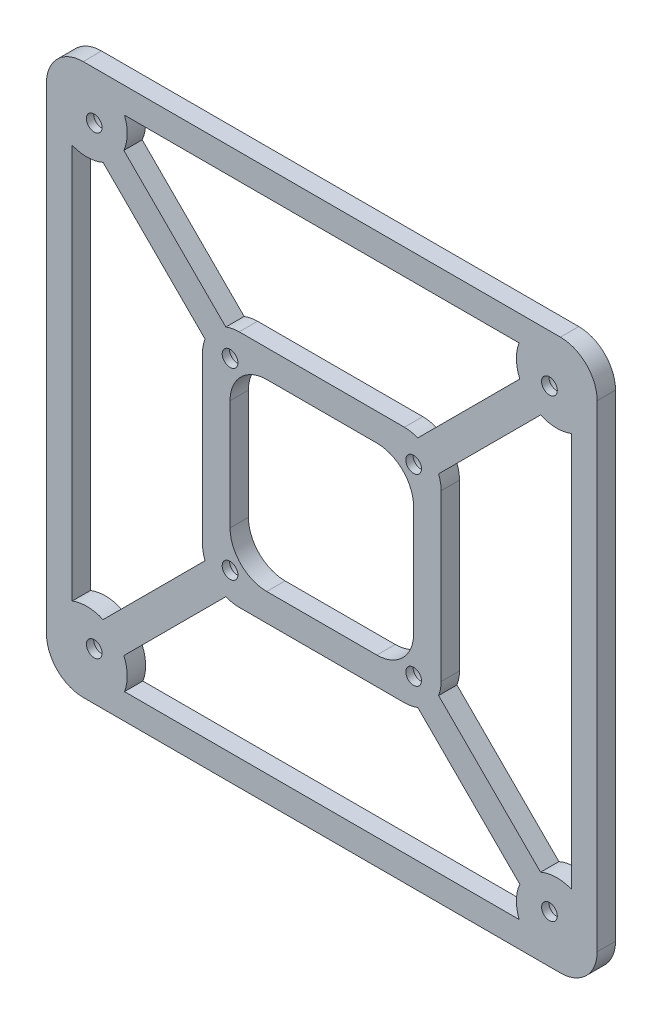
from build123d import *

# Parameters (mm, degrees)
SKETCH1_R             = 11
BOSS_EXTRUDE1_DEPTH   = 5
BOSS_EXTRUDE1_2_DEPTH = 5
BOSS_EXTRUDE1_3_DEPTH = 5
BOSS_EXTRUDE1_4_DEPTH = 5
SKETCH3_W             = 150
SKETCH3_H             = 150
SKETCH3_W_2           = 136
SKETCH3_H_2           = 136
BOSS_EXTRUDE3_DEPTH   = 5
SKETCH8_R             = 2.14
BOSS_EXTRUDE4_DEPTH   = 5
BOSS_EXTRUDE4_2_DEPTH = 5
BOSS_EXTRUDE4_3_DEPTH = 5
BOSS_EXTRUDE4_4_DEPTH = 5
FILLET1_R             = 10
SKETCH9_R             = 4
BOSS_EXTRUDE5_DEPTH   = 3
BOSS_EXTRUDE5_2_DEPTH = 3
BOSS_EXTRUDE5_3_DEPTH = 3
BOSS_EXTRUDE5_4_DEPTH = 3
SKETCH10_W            = 65
SKETCH10_H            = 65
SKETCH10_W_2          = 50
SKETCH10_H_2          = 50
BOSS_EXTRUDE6_DEPTH   = 5
FILLET2_R             = 10
SKETCH11_R            = 2.14
BOSS_EXTRUDE7_DEPTH   = 5
BOSS_EXTRUDE7_2_DEPTH = 5
BOSS_EXTRUDE7_3_DEPTH = 5
BOSS_EXTRUDE7_4_DEPTH = 5
SKETCH12_R            = 3.8
BOSS_EXTRUDE8_DEPTH   = 3
BOSS_EXTRUDE8_2_DEPTH = 3
BOSS_EXTRUDE8_3_DEPTH = 3
BOSS_EXTRUDE8_4_DEPTH = 3
BOSS_EXTRUDE9_DEPTH   = 5
BOSS_EXTRUDE9_2_DEPTH = 5
BOSS_EXTRUDE9_3_DEPTH = 5
BOSS_EXTRUDE9_4_DEPTH = 5


with BuildPart() as part:
    # Sketch1 → Boss-Extrude1 (new body)
    with BuildSketch(Plane.XY):
        with Locations((-64, -64)):
            Circle(SKETCH1_R)
    extrude(amount=BOSS_EXTRUDE1_DEPTH)


with BuildPart() as body_2:
    # Sketch1 → Boss-Extrude1 2 (new body)
    with BuildSketch(Plane.XY):
        with Locations((-64, 64)):
            Circle(SKETCH1_R)
    extrude(amount=BOSS_EXTRUDE1_2_DEPTH)



with BuildPart() as body_3:
    # Sketch1 → Boss-Extrude1 3 (new body)
    with BuildSketch(Plane.XY):
        with Locations((64, -64)):
            Circle(SKETCH1_R)
    extrude(amount=BOSS_EXTRUDE1_3_DEPTH)


with BuildPart() as body_4:
    # Sketch1 → Boss-Extrude1 4 (new body)
    with BuildSketch(Plane.XY):
        with Locations((64, 64)):
            Circle(SKETCH1_R)
    extrude(amount=BOSS_EXTRUDE1_4_DEPTH)


with BuildPart() as body_2_1:
    add(body_2.part)

    add(body_3.part)  # Boss-Extrude3 merges body 3

    add(body_4.part)  # Boss-Extrude3 merges body 4
    # Sketch3 → Boss-Extrude3 (add)
    with BuildSketch(Plane.XY):
        Rectangle(SKETCH3_W, SKETCH3_H)
        Rectangle(SKETCH3_W_2, SKETCH3_H_2, mode=Mode.SUBTRACT)
    extrude(amount=BOSS_EXTRUDE3_DEPTH)

    # Fillet1
    fillet1_edges = [body_2_1.edges().sort_by_distance(p)[0] for p in [
        (75, -75, 2.5),
        (75, 75, 2.5),
        (-75, 75, 2.5),
        (-75, -75, 2.5),
    ]]
    fillet(fillet1_edges, radius=FILLET1_R)

    # Combine1: union part
    add(part.part)


with BuildPart() as body_3_2:
    # Sketch8 → Boss-Extrude4 (new body)
    with BuildSketch(Plane.XY):
        with Locations((-62, 62)):
            Circle(SKETCH8_R)
    extrude(amount=BOSS_EXTRUDE4_DEPTH)


with BuildPart() as body_4_2:
    # Sketch8 → Boss-Extrude4 2 (new body)
    with BuildSketch(Plane.XY):
        with Locations((-62, -62)):
            Circle(SKETCH8_R)
    extrude(amount=BOSS_EXTRUDE4_2_DEPTH)


with BuildPart() as body_5:
    # Sketch8 → Boss-Extrude4 3 (new body)
    with BuildSketch(Plane.XY):
        with Locations((62, 62)):
            Circle(SKETCH8_R)
    extrude(amount=BOSS_EXTRUDE4_3_DEPTH)


with BuildPart() as body_6:
    # Sketch8 → Boss-Extrude4 4 (new body)
    with BuildSketch(Plane.XY):
        with Locations((62, -62)):
            Circle(SKETCH8_R)
    extrude(amount=BOSS_EXTRUDE4_4_DEPTH)


with BuildPart() as body_6_2:
    # Sketch9 → Boss-Extrude5 (new body)
    with BuildSketch(Plane.XY):
        with Locations((-62, 62)):
            Circle(SKETCH9_R)
    extrude(amount=BOSS_EXTRUDE5_DEPTH)


with BuildPart() as body_7:
    # Sketch9 → Boss-Extrude5 2 (new body)
    with BuildSketch(Plane.XY):
        with Locations((-62, -62)):
            Circle(SKETCH9_R)
    extrude(amount=BOSS_EXTRUDE5_2_DEPTH)


with BuildPart() as body_8:
    # Sketch9 → Boss-Extrude5 3 (new body)
    with BuildSketch(Plane.XY):
        with Locations((62, 62)):
            Circle(SKETCH9_R)
    extrude(amount=BOSS_EXTRUDE5_3_DEPTH)


with BuildPart() as body_9:
    # Sketch9 → Boss-Extrude5 4 (new body)
    with BuildSketch(Plane.XY):
        with Locations((62, -62)):
            Circle(SKETCH9_R)
    extrude(amount=BOSS_EXTRUDE5_4_DEPTH)


with BuildPart() as body_10:
    # Sketch10 → Boss-Extrude6 (new body)
    with BuildSketch(Plane.XY):
        Rectangle(SKETCH10_W, SKETCH10_H)
        Rectangle(SKETCH10_W_2, SKETCH10_H_2, mode=Mode.SUBTRACT)
    extrude(amount=BOSS_EXTRUDE6_DEPTH)

    # Fillet2
    fillet2_edges = [body_10.edges().sort_by_distance(p)[0] for p in [
        (-25, -25, 2.5),
        (25, -25, 2.5),
        (-25, 25, 2.5),
        (25, 25, 2.5),
        (32.5, -32.5, 2.5),
        (-32.5, -32.5, 2.5),
        (-32.5, 32.5, 2.5),
        (32.5, 32.5, 2.5),
    ]]
    fillet(fillet2_edges, radius=FILLET2_R)


with BuildPart() as body_11:
    # Sketch11 → Boss-Extrude7 (new body)
    with BuildSketch(Plane.XY):
        with Locations((25, 25)):
            Circle(SKETCH11_R)
    extrude(amount=BOSS_EXTRUDE7_DEPTH)


with BuildPart() as body_12:
    # Sketch11 → Boss-Extrude7 2 (new body)
    with BuildSketch(Plane.XY):
        with Locations((-25, 25)):
            Circle(SKETCH11_R)
    extrude(amount=BOSS_EXTRUDE7_2_DEPTH)


with BuildPart() as body_13:
    # Sketch11 → Boss-Extrude7 3 (new body)
    with BuildSketch(Plane.XY):
        with Locations((-25, -25)):
            Circle(SKETCH11_R)
    extrude(amount=BOSS_EXTRUDE7_3_DEPTH)


with BuildPart() as body_14:
    # Sketch11 → Boss-Extrude7 4 (new body)
    with BuildSketch(Plane.XY):
        with Locations((25, -25)):
            Circle(SKETCH11_R)
    extrude(amount=BOSS_EXTRUDE7_4_DEPTH)


with BuildPart() as body_15:
    # Sketch12 → Boss-Extrude8 (new body)
    with BuildSketch(Plane.XY):
        with Locations((25, 25)):
            Circle(SKETCH12_R)
    extrude(amount=BOSS_EXTRUDE8_DEPTH)


with BuildPart() as body_16:
    # Sketch12 → Boss-Extrude8 2 (new body)
    with BuildSketch(Plane.XY):
        with Locations((-25, 25)):
            Circle(SKETCH12_R)
    extrude(amount=BOSS_EXTRUDE8_2_DEPTH)


with BuildPart() as body_17:
    # Sketch12 → Boss-Extrude8 3 (new body)
    with BuildSketch(Plane.XY):
        with Locations((-25, -25)):
            Circle(SKETCH12_R)
    extrude(amount=BOSS_EXTRUDE8_3_DEPTH)


with BuildPart() as body_18:
    # Sketch12 → Boss-Extrude8 4 (new body)
    with BuildSketch(Plane.XY):
        with Locations((25, -25)):
            Circle(SKETCH12_R)
    extrude(amount=BOSS_EXTRUDE8_4_DEPTH)


with BuildPart() as body_19:
    # Sketch14 → Boss-Extrude9 (new body)
    with BuildSketch(Plane.XY):
        with BuildLine():
            Line((-59.171572875, 64.828427125), (-22.171572875, 27.828427125))
            ThreePointArc((-22.171572875, 27.828427125), (-22.171572875, 22.171572875), (-27.828427125, 22.171572875))
            Line((-27.828427125, 22.171572875), (-64.828427125, 59.171572875))
            ThreePointArc((-64.828427125, 59.171572875), (-64.828427125, 64.828427125), (-59.171572875, 64.828427125))
        make_face()
    extrude(amount=BOSS_EXTRUDE9_DEPTH)


with BuildPart() as body_20:
    # Sketch14 → Boss-Extrude9 2 (new body)
    with BuildSketch(Plane.XY):
        with BuildLine():
            Line((64.828427125, 59.171572875), (27.828427125, 22.171572875))
            ThreePointArc((27.828427125, 22.171572875), (22.171572875, 22.171572875), (22.171572875, 27.828427125))
            Line((22.171572875, 27.828427125), (59.171572875, 64.828427125))
            ThreePointArc((59.171572875, 64.828427125), (64.828427125, 64.828427125), (64.828427125, 59.171572875))
        make_face()
    extrude(amount=BOSS_EXTRUDE9_2_DEPTH)


with BuildPart() as body_21:
    # Sketch14 → Boss-Extrude9 3 (new body)
    with BuildSketch(Plane.XY):
        with BuildLine():
            Line((27.828427125, -22.171572875), (64.828427125, -59.171572875))
            ThreePointArc((64.828427125, -59.171572875), (64.828427125, -64.828427125), (59.171572875, -64.828427125))
            Line((59.171572875, -64.828427125), (22.171572875, -27.828427125))
            ThreePointArc((22.171572875, -27.828427125), (22.171572875, -22.171572875), (27.828427125, -22.171572875))
        make_face()
    extrude(amount=BOSS_EXTRUDE9_3_DEPTH)


with BuildPart() as body_22:
    # Sketch14 → Boss-Extrude9 4 (new body)
    with BuildSketch(Plane.XY):
        with BuildLine():
            Line((-22.171572875, -27.828427125), (-59.171572875, -64.828427125))
            ThreePointArc((-59.171572875, -64.828427125), (-64.828427125, -64.828427125), (-64.828427125, -59.171572875))
            Line((-64.828427125, -59.171572875), (-27.828427125, -22.171572875))
            ThreePointArc((-27.828427125, -22.171572875), (-22.171572875, -22.171572875), (-22.171572875, -27.828427125))
        make_face()
    extrude(amount=BOSS_EXTRUDE9_4_DEPTH)

    # Combine4: union body 21, body 20, body 19, body 2, body 10
    add(body_21.part)
    add(body_20.part)
    add(body_19.part)
    add(body_2_1.part)
    add(body_10.part)

    # Combine5: cut body 15, body 18, body 17, body 16, body 11, body 14, body 13, body 12, body 9, body 6 2, body 8, body 7, body 6, body 3 2, body 5, body 4 2
    add(body_15.part, mode=Mode.SUBTRACT)
    add(body_18.part, mode=Mode.SUBTRACT)
    add(body_17.part, mode=Mode.SUBTRACT)
    add(body_16.part, mode=Mode.SUBTRACT)
    add(body_11.part, mode=Mode.SUBTRACT)
    add(body_14.part, mode=Mode.SUBTRACT)
    add(body_13.part, mode=Mode.SUBTRACT)
    add(body_12.part, mode=Mode.SUBTRACT)
    add(body_9.part, mode=Mode.SUBTRACT)
    add(body_6_2.part, mode=Mode.SUBTRACT)
    add(body_8.part, mode=Mode.SUBTRACT)
    add(body_7.part, mode=Mode.SUBTRACT)
    add(body_6.part, mode=Mode.SUBTRACT)
    add(body_3_2.part, mode=Mode.SUBTRACT)
    add(body_5.part, mode=Mode.SUBTRACT)
    add(body_4_2.part, mode=Mode.SUBTRACT)


solid = body_22.part
